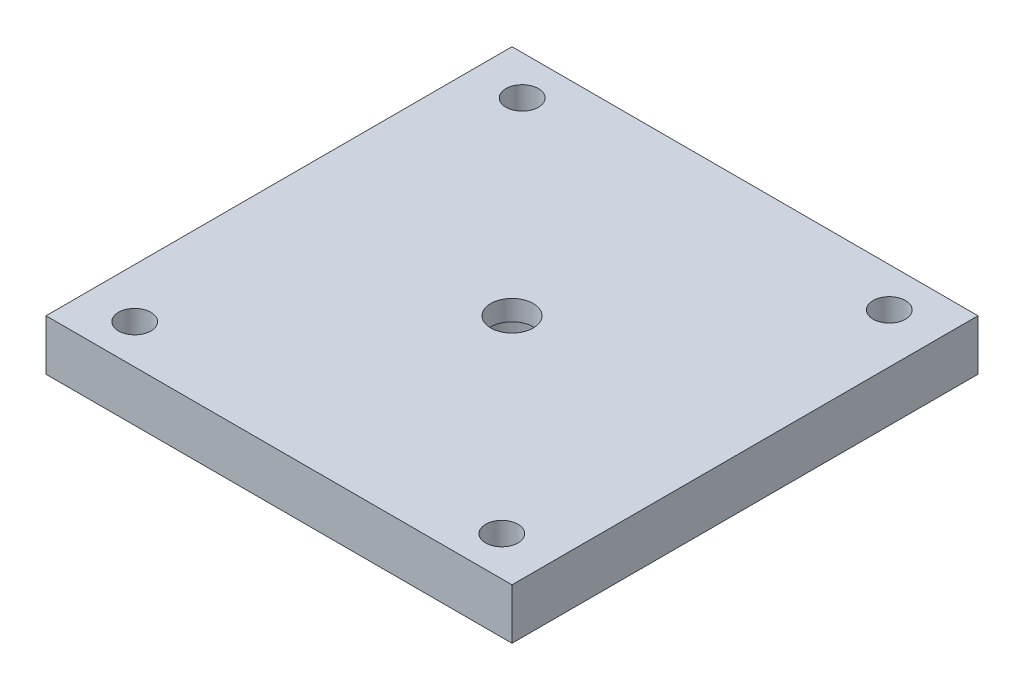
from build123d import *

# Parameters (mm, degrees)
SKETCH2_W           = 46
SKETCH2_H           = 46
BOSS_EXTRUDE1_DEPTH = 5
SKETCH4_R           = 4.1
CUT_EXTRUDE2_DEPTH  = 3
SKETCH5_R           = 2.1
CUT_EXTRUDE4_DEPTH  = 6
SKETCH6_R           = 1.6
CUT_EXTRUDE5_DEPTH  = 5


with BuildPart() as part:
    # Sketch2 → Boss-Extrude1 (new body)
    with BuildSketch(Plane(origin=(0, 0, 0), x_dir=(1, 0, 0), z_dir=(0, 1, 0))):
        Rectangle(SKETCH2_W, SKETCH2_H)
    extrude(amount=BOSS_EXTRUDE1_DEPTH)

    # Sketch4 → Cut-Extrude2 (cut)
    with BuildSketch(Plane(origin=(0, 0, 0), x_dir=(1, 0, 0), z_dir=(0, 1, 0))):
        Circle(SKETCH4_R)
    extrude(amount=CUT_EXTRUDE2_DEPTH, mode=Mode.SUBTRACT)

    # Sketch5 → Cut-Extrude4 (cut, through all)
    with BuildSketch(Plane(origin=(0, 0, 0), x_dir=(1, 0, 0), z_dir=(0, 1, 0))):
        Circle(SKETCH5_R)
    extrude(amount=CUT_EXTRUDE4_DEPTH, mode=Mode.SUBTRACT)

    # Sketch6 → Cut-Extrude5 (cut)
    with BuildSketch(Plane(origin=(0, 0, 0), x_dir=(1, 0, 0), z_dir=(0, 1, 0))):
        with Locations((18.12, 19.125)):
            Circle(SKETCH6_R)
        with Locations((-18.12, 19.125)):
            Circle(SKETCH6_R)
        with Locations((-18.12, -19.125)):
            Circle(SKETCH6_R)
        with Locations((18.12, -19.125)):
            Circle(SKETCH6_R)
    extrude(amount=CUT_EXTRUDE5_DEPTH, mode=Mode.SUBTRACT)


solid = part.part
